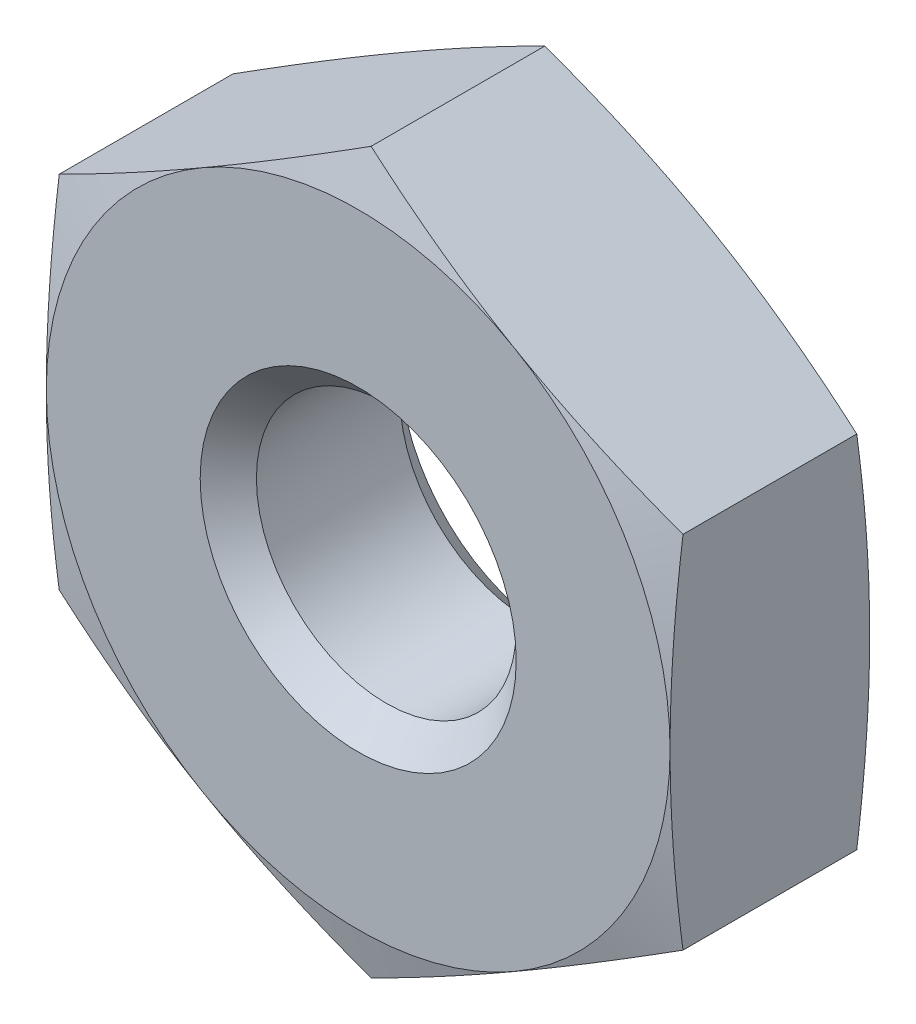
from build123d import *

# Parameters (mm, degrees)
SKETCH2_W          = 19.05
SKETCH2_H          = 19.05
CUT_EXTRUDE1_DEPTH = 3.048


with BuildPart() as part:
    # Sketch1 → Revolve1 (revolve)
    with BuildSketch(Plane(origin=(0, 0, 0), x_dir=(0, 0, -1), z_dir=(1, 0, 0))):
        Polygon((0, 0), (0, 4.7625), (0.255221606, 5.715), (2.792778394, 5.715), (3.048, 4.7625), (3.048, 0), align=None)
    revolve(axis=Axis((0, 0, -3.048), (0, 0, 1)))

    # Sketch2 → Cut-Extrude1 (cut)
    with BuildSketch(Plane.XY):
        Rectangle(SKETCH2_W, SKETCH2_H)
        Polygon((-4.7625, 2.749630657), (-4.7625, -2.749630657), (0, -5.499261314), (4.7625, -2.749630657), (4.7625, 2.749630657), (0, 5.499261314), align=None, mode=Mode.SUBTRACT)
    extrude(amount=-CUT_EXTRUDE1_DEPTH, mode=Mode.SUBTRACT)

    # Sketch3 → Cut-Revolve1 (revolve, cut)
    with BuildSketch(Plane(origin=(0, 0, 0), x_dir=(0, 0, -1), z_dir=(1, 0, 0))):
        Polygon((0, 0), (0, 2.413), (0.42926, 1.98374), (2.61874, 1.98374), (3.048, 2.413), (3.048, 0), align=None)
    revolve(axis=Axis((0, 0, -3.048), (0, 0, 1)), mode=Mode.SUBTRACT)


solid = part.part
